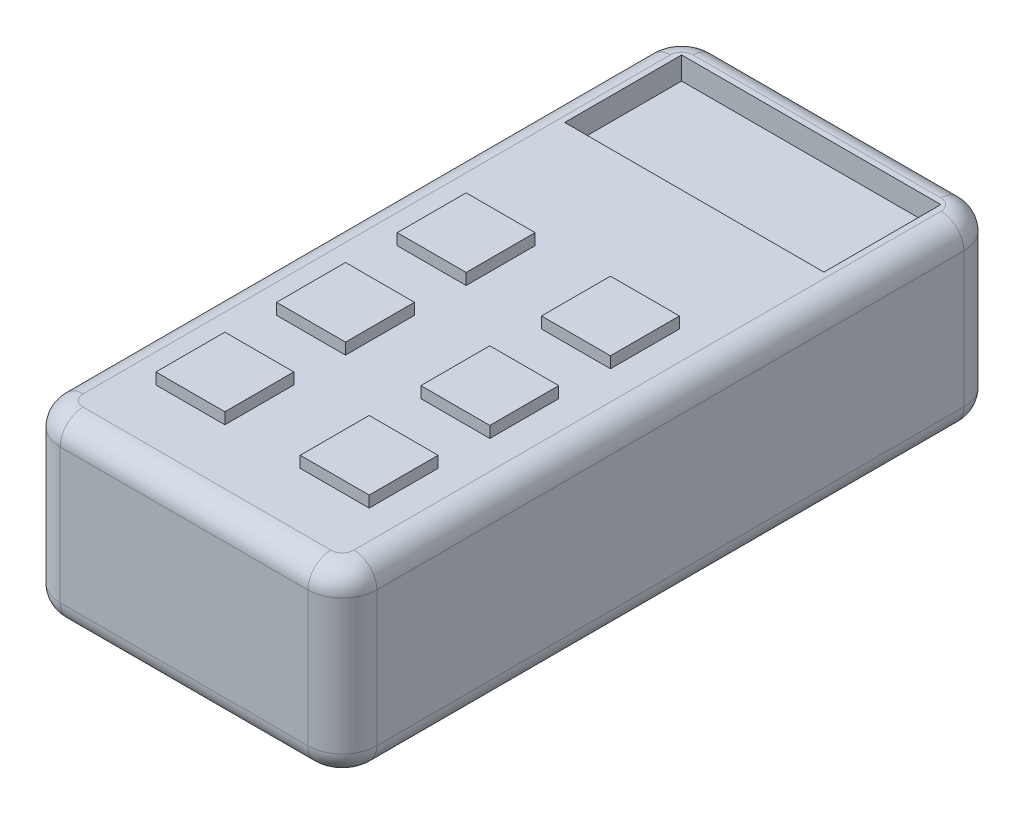
from build123d import *

# Parameters (mm, degrees)
SKETCH1_W           = 70
SKETCH1_H           = 145
BOSS_EXTRUDE1_DEPTH = 40
SKETCH2_W           = 57.3
SKETCH2_H           = 25.847658175
CUT_EXTRUDE1_DEPTH  = 5
SKETCH3_W           = 15.24
SKETCH3_H           = 15.24
BOSS_EXTRUDE2_DEPTH = 2.5
LPATTERN1_COUNT     = 3
LPATTERN1_PITCH     = 26.67
FILLET1_R           = 7.62
FILLET2_R           = 5.08
FILLET3_R           = 5.08


with BuildPart() as part:
    # Sketch1 → Boss-Extrude1 (new body)
    with BuildSketch(Plane(origin=(0, 0, 0), x_dir=(1, 0, 0), z_dir=(0, 1, 0))):
        Rectangle(SKETCH1_W, SKETCH1_H)
    extrude(amount=BOSS_EXTRUDE1_DEPTH)

    # Sketch2 → Cut-Extrude1 (cut)
    with BuildSketch(Plane(origin=(0, 40, 0), x_dir=(1, 0, 0), z_dir=(0, 1, 0))):
        with Locations((0, 53.226170913)):
            Rectangle(SKETCH2_W, SKETCH2_H)
    extrude(amount=-CUT_EXTRUDE1_DEPTH, mode=Mode.SUBTRACT)

    # Sketch3 → Boss-Extrude2 (add)
    with BuildSketch(Plane(origin=(0, 40, 0), x_dir=(1, 0, 0), z_dir=(0, 1, 0))):
        with Locations((-15.95, 5.814113942)):
            Rectangle(SKETCH3_W, SKETCH3_H)
        with Locations((15.95, 5.814113942)):
            Rectangle(SKETCH3_W, SKETCH3_H)
    boss_extrude2 = extrude(amount=BOSS_EXTRUDE2_DEPTH)

    # LPattern1: Boss-Extrude2 ×3
    with Locations(*[(0, 0, i * LPATTERN1_PITCH) for i in range(1, LPATTERN1_COUNT)]):
        add(boss_extrude2)

    # Fillet1
    fillet1_edges = [part.edges().sort_by_distance(p)[0] for p in [
        (35, 20, 72.5),
        (-35, 20, 72.5),
        (-35, 20, -72.5),
        (35, 20, -72.5),
    ]]
    fillet(fillet1_edges, radius=FILLET1_R)

    # Fillet2
    fillet2_edges = [part.edges().sort_by_distance(p)[0] for p in [
        (35, 40, 0),
        (0, 40, 72.5),
        (0, 40, -72.5),
        (-35, 40, 0),
        (32.768153673, 40, -70.268153673),
        (-32.768153673, 40, -70.268153673),
        (-32.768153673, 40, 70.268153673),
        (32.768153673, 40, 70.268153673),
    ]]
    fillet(fillet2_edges, radius=FILLET2_R)

    # Fillet3
    fillet3_edges = [part.edges().sort_by_distance(p)[0] for p in [
        (35, 0, 0),
        (0, 0, 72.5),
        (-35, 0, 0),
        (0, 0, -72.5),
        (32.768153673, 0, -70.268153673),
        (-32.768153673, 0, -70.268153673),
        (-32.768153673, 0, 70.268153673),
        (32.768153673, 0, 70.268153673),
    ]]
    fillet(fillet3_edges, radius=FILLET3_R)


solid = part.part
